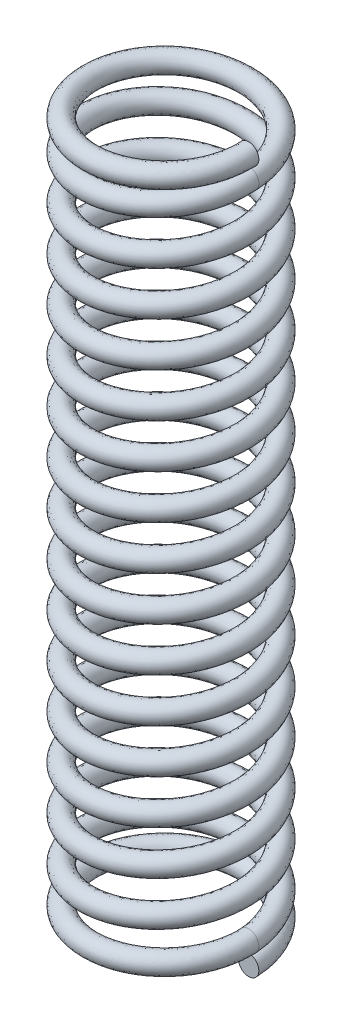
from build123d import *

# Parameters (mm, degrees)
SWEEP1_PITCH       = 1.591733333
SWEEP1_HEIGHT      = 23.876
SWEEP1_RADIUS      = 3.175
SWEEP1_START_ANGLE = 90
SKETCH1_R          = 0.3683
SWEEP2_PITCH       = 0.762
SWEEP2_HEIGHT      = 0.762
SWEEP2_RADIUS      = 3.175
SWEEP2_START_ANGLE = 90
SKETCH5_R          = 0.3683
SWEEP3_PITCH       = 0.762
SWEEP3_HEIGHT      = 0.762
SWEEP3_RADIUS      = 3.175
SWEEP3_START_ANGLE = 90
SKETCH7_R          = 0.3683


with BuildPart() as part:
    # Sweep1: sweep along a helix
    with BuildLine() as sweep1_path:
        add(Helix(SWEEP1_PITCH, SWEEP1_HEIGHT, SWEEP1_RADIUS, center=(0, 0.762, 0), direction=(0, 1, 0), mode=Mode.PRIVATE).rotate(Axis((0, 0.762, 0), (0, 1, 0)), SWEEP1_START_ANGLE))
    # Sketch1 → Sweep1 (sweep)
    with BuildSketch(Plane.XY):
        with Locations((2.8067, 0.762)):
            Circle(SKETCH1_R)
    sweep(path=sweep1_path.line, is_frenet=True)

    # Sweep2: sweep along a helix
    with BuildLine() as sweep2_path:
        add(Helix(SWEEP2_PITCH, SWEEP2_HEIGHT, SWEEP2_RADIUS, center=(0, 0.762, 0), direction=(0, -1, 0), mode=Mode.PRIVATE).rotate(Axis((0, 0.762, 0), (0, -1, 0)), SWEEP2_START_ANGLE))
    # Sketch5 → Sweep2 (sweep)
    with BuildSketch(Plane.XY):
        with Locations((2.8067, 0)):
            Circle(SKETCH5_R)
    sweep(path=sweep2_path.line, is_frenet=True)

    # Sweep3: sweep along a helix
    with BuildLine() as sweep3_path:
        add(Helix(SWEEP3_PITCH, SWEEP3_HEIGHT, SWEEP3_RADIUS, center=(0, 24.638, 0), direction=(0, 1, 0), mode=Mode.PRIVATE).rotate(Axis((0, 24.638, 0), (0, 1, 0)), SWEEP3_START_ANGLE))
    # Sketch7 → Sweep3 (sweep)
    with BuildSketch(Plane.XY):
        with Locations((2.8067, 24.638)):
            Circle(SKETCH7_R)
    sweep(path=sweep3_path.line, is_frenet=True)


solid = part.part
